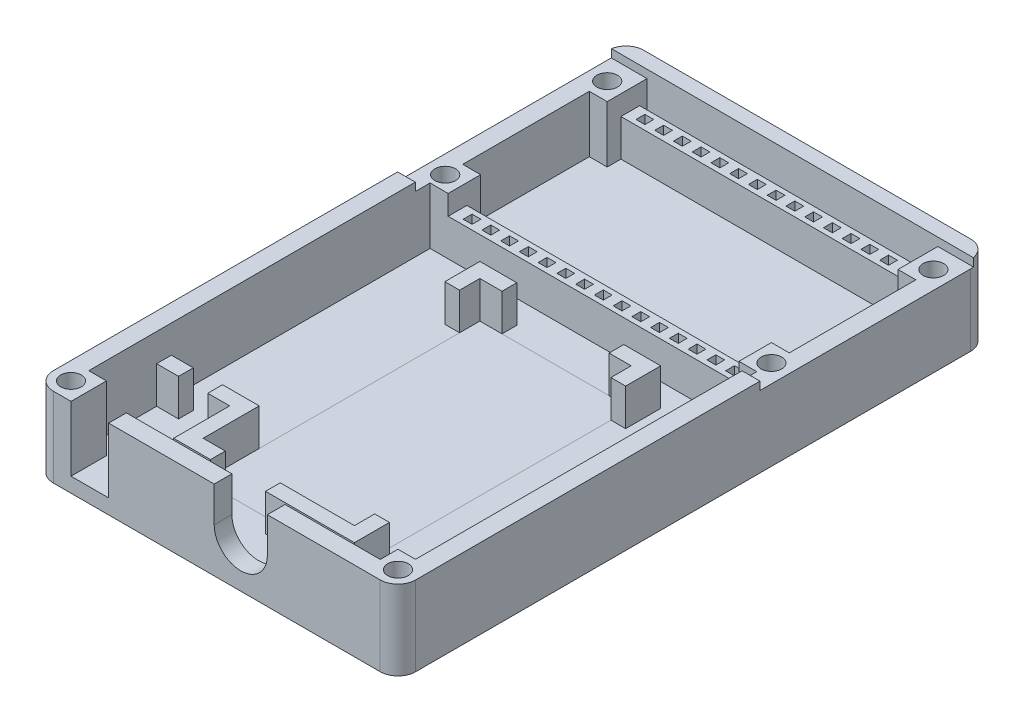
from build123d import *

# Parameters (mm, degrees)
SKETCH1_W           = 49.1
SKETCH1_H           = 80
BOSS_EXTRUDE1_DEPTH = 2
SKETCH2_R           = 1.4
CUT_EXTRUDE1_DEPTH  = 2
SKETCH3_R           = 1.4
SKETCH3_W           = 1.2
SKETCH3_H           = 1.2
BOSS_EXTRUDE2_DEPTH = 5
SKETCH4_W           = 4.85
SKETCH4_H           = 4.4
SKETCH4_R           = 1.4
BOSS_EXTRUDE3_DEPTH = 2.68
SKETCH5_W           = 7.047350567
SKETCH5_H           = 2
SKETCH5_W_2         = 0.952649433
BOSS_EXTRUDE4_DEPTH = 5
SKETCH6_W           = 4.8
SKETCH6_H           = 4.8
SKETCH6_R           = 1.4
BOSS_EXTRUDE5_DEPTH = 8.78
SKETCH7_W           = 2.4
SKETCH7_H           = 46.25
SKETCH7_W_2         = 2.425
SKETCH7_W_3         = 39.5
SKETCH7_H_2         = 2.4
BOSS_EXTRUDE6_DEPTH = 8.78
CUT_EXTRUDE2_DEPTH  = 2.4
SKETCH11_R          = 1.4
CUT_EXTRUDE4_DEPTH  = 2
SKETCH13_W          = 2.97
SKETCH13_H          = 2
BOSS_EXTRUDE7_DEPTH = 5
SKETCH14_W          = 2.425
SKETCH14_H          = 17.15
BOSS_EXTRUDE8_DEPTH = 2.68
CUT_EXTRUDE5_DEPTH  = 5
SKETCH17_W          = 4.85
SKETCH17_H          = 0.6
SKETCH17_W_2        = 2.4
SKETCH17_H_2        = 2
SKETCH17_W_3        = 2.425
CUT_EXTRUDE6_DEPTH  = 1.1
FILLET1_R           = 2.4


with BuildPart() as part:
    # Sketch1 → Boss-Extrude1 (new body)
    with BuildSketch(Plane(origin=(0, 0, 0), x_dir=(1, 0, 0), z_dir=(0, 1, 0))):
        with Locations((24.55, -40)):
            Rectangle(SKETCH1_W, SKETCH1_H)
    extrude(amount=BOSS_EXTRUDE1_DEPTH)

    # Sketch2 → Cut-Extrude1 (cut)
    with BuildSketch(Plane(origin=(0, 2, 0), x_dir=(1, 0, 0), z_dir=(0, 1, 0))):
        with Locations((2.45, -5)):
            Circle(SKETCH2_R)
        with Locations((46.65, -5)):
            Circle(SKETCH2_R)
        with Locations((46.65, -26.95)):
            Circle(SKETCH2_R)
        with Locations((2.45, -26.95)):
            Circle(SKETCH2_R)
    extrude(amount=-CUT_EXTRUDE1_DEPTH, mode=Mode.SUBTRACT)

    # Sketch3 → Boss-Extrude2 (add)
    with BuildSketch(Plane(origin=(0, 2, 0), x_dir=(1, 0, 0), z_dir=(0, 1, 0))):
        Polygon((4.85, -3), (44.25, -3), (44.25, -2.6), (49.1, -2.6), (49.1, -3), (49.1, -28.95), (0, -28.95), (0, -3), (0, -2.6), (4.85, -2.6), align=None)
        with Locations((2.45, -5)):
            Circle(SKETCH3_R, mode=Mode.SUBTRACT)
        with Locations((2.45, -26.95)):
            Circle(SKETCH3_R, mode=Mode.SUBTRACT)
        with Locations((46.65, -5)):
            Circle(SKETCH3_R, mode=Mode.SUBTRACT)
        with Locations((46.65, -26.95)):
            Circle(SKETCH3_R, mode=Mode.SUBTRACT)
        with Locations((6.82, -4.27)):
            Rectangle(SKETCH3_W, SKETCH3_H, mode=Mode.SUBTRACT)
        with Locations((9.36, -4.27)):
            Rectangle(SKETCH3_W, SKETCH3_H, mode=Mode.SUBTRACT)
        with Locations((11.9, -4.27)):
            Rectangle(SKETCH3_W, SKETCH3_H, mode=Mode.SUBTRACT)
        with Locations((14.44, -4.27)):
            Rectangle(SKETCH3_W, SKETCH3_H, mode=Mode.SUBTRACT)
        with Locations((16.98, -4.27)):
            Rectangle(SKETCH3_W, SKETCH3_H, mode=Mode.SUBTRACT)
        with Locations((19.52, -4.27)):
            Rectangle(SKETCH3_W, SKETCH3_H, mode=Mode.SUBTRACT)
        with Locations((22.06, -4.27)):
            Rectangle(SKETCH3_W, SKETCH3_H, mode=Mode.SUBTRACT)
        with Locations((24.6, -4.27)):
            Rectangle(SKETCH3_W, SKETCH3_H, mode=Mode.SUBTRACT)
        with Locations((27.14, -4.27)):
            Rectangle(SKETCH3_W, SKETCH3_H, mode=Mode.SUBTRACT)
        with Locations((29.68, -4.27)):
            Rectangle(SKETCH3_W, SKETCH3_H, mode=Mode.SUBTRACT)
        with Locations((32.22, -4.27)):
            Rectangle(SKETCH3_W, SKETCH3_H, mode=Mode.SUBTRACT)
        with Locations((34.76, -4.27)):
            Rectangle(SKETCH3_W, SKETCH3_H, mode=Mode.SUBTRACT)
        with Locations((37.3, -4.27)):
            Rectangle(SKETCH3_W, SKETCH3_H, mode=Mode.SUBTRACT)
        with Locations((39.84, -4.27)):
            Rectangle(SKETCH3_W, SKETCH3_H, mode=Mode.SUBTRACT)
        with Locations((42.38, -4.27)):
            Rectangle(SKETCH3_W, SKETCH3_H, mode=Mode.SUBTRACT)
        with Locations((42.38, -27.68)):
            Rectangle(SKETCH3_W, SKETCH3_H, mode=Mode.SUBTRACT)
        with Locations((39.84, -27.68)):
            Rectangle(SKETCH3_W, SKETCH3_H, mode=Mode.SUBTRACT)
        with Locations((37.3, -27.68)):
            Rectangle(SKETCH3_W, SKETCH3_H, mode=Mode.SUBTRACT)
        with Locations((34.76, -27.68)):
            Rectangle(SKETCH3_W, SKETCH3_H, mode=Mode.SUBTRACT)
        with Locations((32.22, -27.68)):
            Rectangle(SKETCH3_W, SKETCH3_H, mode=Mode.SUBTRACT)
        with Locations((29.68, -27.68)):
            Rectangle(SKETCH3_W, SKETCH3_H, mode=Mode.SUBTRACT)
        with Locations((27.14, -27.68)):
            Rectangle(SKETCH3_W, SKETCH3_H, mode=Mode.SUBTRACT)
        with Locations((24.6, -27.68)):
            Rectangle(SKETCH3_W, SKETCH3_H, mode=Mode.SUBTRACT)
        with Locations((22.06, -27.68)):
            Rectangle(SKETCH3_W, SKETCH3_H, mode=Mode.SUBTRACT)
        with Locations((19.52, -27.68)):
            Rectangle(SKETCH3_W, SKETCH3_H, mode=Mode.SUBTRACT)
        with Locations((16.98, -27.68)):
            Rectangle(SKETCH3_W, SKETCH3_H, mode=Mode.SUBTRACT)
        with Locations((14.44, -27.68)):
            Rectangle(SKETCH3_W, SKETCH3_H, mode=Mode.SUBTRACT)
        with Locations((11.9, -27.68)):
            Rectangle(SKETCH3_W, SKETCH3_H, mode=Mode.SUBTRACT)
        with Locations((9.36, -27.68)):
            Rectangle(SKETCH3_W, SKETCH3_H, mode=Mode.SUBTRACT)
        with Locations((6.82, -27.68)):
            Rectangle(SKETCH3_W, SKETCH3_H, mode=Mode.SUBTRACT)
    extrude(amount=BOSS_EXTRUDE2_DEPTH)

    # Sketch4 → Boss-Extrude3 (add)
    with BuildSketch(Plane(origin=(0, 7, 0), x_dir=(1, 0, 0), z_dir=(0, 1, 0))):
        with Locations((2.425, -26.75)):
            Rectangle(SKETCH4_W, SKETCH4_H)
        with Locations((2.45, -26.95)):
            Circle(SKETCH4_R, mode=Mode.SUBTRACT)
        with Locations((46.675, -26.75)):
            Rectangle(SKETCH4_W, SKETCH4_H)
        with Locations((46.65, -26.95)):
            Circle(SKETCH4_R, mode=Mode.SUBTRACT)
        Polygon((49.1, -7.4), (49.1, -3), (49.1, -2.6), (44.25, -2.6), (44.25, -3), (44.25, -7.4), align=None)
        with Locations((46.65, -5)):
            Circle(SKETCH4_R, mode=Mode.SUBTRACT)
        Polygon((4.85, -7.4), (4.85, -3), (4.85, -2.6), (0, -2.6), (0, -3), (0, -7.4), align=None)
        with Locations((2.45, -5)):
            Circle(SKETCH4_R, mode=Mode.SUBTRACT)
    extrude(amount=BOSS_EXTRUDE3_DEPTH)

    # Sketch5 → Boss-Extrude4 (add)
    with BuildSketch(Plane(origin=(0, 2, 0), x_dir=(1, 0, 0), z_dir=(0, 1, 0))):
        Polygon((14.3, -36.85), (14.3, -34.1), (17.3, -34.1), (17.3, -32.1), (12.3, -32.1), (12.3, -36.85), align=None)
        Polygon((31.8, -32.1), (31.8, -34.1), (34.8, -34.1), (34.8, -36.85), (36.8, -36.85), (36.8, -32.1), align=None)
        Polygon((36.8, -68.85), (34.8, -68.85), (34.8, -71.6), (32.752649433, -71.6), (32.752649433, -73.6), (36.8, -73.6), align=None)
        Polygon((14.3, -71.6), (14.3, -68.85), (12.3, -68.85), (12.3, -73.6), (17.3, -73.6), (17.3, -71.6), align=None)
        with Locations((28.276324716, -72.6)):
            Rectangle(SKETCH5_W, SKETCH5_H)
        with Locations((32.276324716, -72.6)):
            Rectangle(SKETCH5_W_2, SKETCH5_H)
    extrude(amount=BOSS_EXTRUDE4_DEPTH)

    # Sketch6 → Boss-Extrude5 (add)
    with BuildSketch(Plane(origin=(0, 2, 0), x_dir=(1, 0, 0), z_dir=(0, 1, 0))):
        with Locations((2.4, -77.6)):
            Rectangle(SKETCH6_W, SKETCH6_H)
        with Locations((2.4, -77.6)):
            Circle(SKETCH6_R, mode=Mode.SUBTRACT)
        with Locations((46.7, -77.6)):
            Rectangle(SKETCH6_W, SKETCH6_H)
        with Locations((46.7, -77.6)):
            Circle(SKETCH6_R, mode=Mode.SUBTRACT)
    extrude(amount=BOSS_EXTRUDE5_DEPTH)

    # Sketch7 → Boss-Extrude6 (add)
    with BuildSketch(Plane(origin=(0, 2, 0), x_dir=(1, 0, 0), z_dir=(0, 1, 0))):
        with Locations((1.2, -52.075)):
            Rectangle(SKETCH7_W, SKETCH7_H)
        with Locations((47.8875, -52.075)):
            Rectangle(SKETCH7_W_2, SKETCH7_H)
        Polygon((0, 0), (49.1, 0), (49.1, -2), (49.1, -2.6), (44.25, -2.6), (44.25, -2), (4.85, -2), (4.85, -2.6), (0, -2.6), (0, -2), align=None)
        with Locations((24.55, -78.8)):
            Rectangle(SKETCH7_W_3, SKETCH7_H_2)
    extrude(amount=BOSS_EXTRUDE6_DEPTH)

    # Sketch8 → Cut-Extrude2 (cut)
    with BuildSketch(Plane.XY.offset(80)):
        Polygon((4.8, 8.2), (4.8, 2), (9.9, 2), (9.9, 8.2), (9.9, 10.78), (4.8, 10.78), align=None)
        with BuildLine():
            Line((24.2, 6), (24.2, 10.78))
            Line((24.2, 10.78), (31.4, 10.78))
            Line((31.4, 10.78), (31.4, 6))
            ThreePointArc((31.4, 6), (27.8, 2.4), (24.2, 6))
        make_face()
    extrude(amount=-CUT_EXTRUDE2_DEPTH, mode=Mode.SUBTRACT)

    # Sketch11 → Cut-Extrude4 (cut)
    with BuildSketch(Plane(origin=(0, 2, 0), x_dir=(1, 0, 0), z_dir=(0, 1, 0))):
        with Locations((2.4, -77.6)):
            Circle(SKETCH11_R)
        with Locations((46.7, -77.6)):
            Circle(SKETCH11_R)
    extrude(amount=-CUT_EXTRUDE4_DEPTH, mode=Mode.SUBTRACT)

    # Sketch13 → Boss-Extrude7 (add)
    with BuildSketch(Plane(origin=(0, 2, 0), x_dir=(1, 0, 0), z_dir=(0, 1, 0))):
        Polygon((12.3, -66), (9.33, -66), (9.33, -64), (14.3, -64), (14.3, -66), (14.3, -68.85), (12.3, -68.85), align=None)
        with Locations((3.885, -65)):
            Rectangle(SKETCH13_W, SKETCH13_H)
    extrude(amount=BOSS_EXTRUDE7_DEPTH)

    # Sketch14 → Boss-Extrude8 (add)
    with BuildSketch(Plane(origin=(0, 7, 0), x_dir=(1, 0, 0), z_dir=(0, 1, 0))):
        with Locations((47.8875, -15.975)):
            Rectangle(SKETCH14_W, SKETCH14_H)
        with Locations((1.2125, -15.975)):
            Rectangle(SKETCH14_W, SKETCH14_H)
    extrude(amount=BOSS_EXTRUDE8_DEPTH)

    # Sketch16 → Cut-Extrude5 (cut)
    with BuildSketch(Plane(origin=(0, 7, 0), x_dir=(1, 0, 0), z_dir=(0, 1, 0))):
        Polygon((4.85, -24.55), (4.85, -26.41), (44.25, -26.41), (44.25, -24.55), (46.675, -24.55), (46.675, -7.4), (44.25, -7.4), (44.25, -5.54), (4.85, -5.54), (4.85, -7.4), (2.425, -7.4), (2.425, -24.55), align=None)
    extrude(amount=-CUT_EXTRUDE5_DEPTH, mode=Mode.SUBTRACT)

    # Sketch17 → Cut-Extrude6 (cut)
    with BuildSketch(Plane(origin=(0, 10.78, 0), x_dir=(1, 0, 0), z_dir=(0, 1, 0))):
        with Locations((2.425, -2.3)):
            Rectangle(SKETCH17_W, SKETCH17_H)
        with Locations((46.675, -2.3)):
            Rectangle(SKETCH17_W, SKETCH17_H)
        with Locations((1.2, -29.95)):
            Rectangle(SKETCH17_W_2, SKETCH17_H_2)
        with Locations((47.8875, -29.95)):
            Rectangle(SKETCH17_W_3, SKETCH17_H_2)
    extrude(amount=-CUT_EXTRUDE6_DEPTH, mode=Mode.SUBTRACT)

    # Fillet1
    fillet1_edges = [part.edges().sort_by_distance(p)[0] for p in [
        (0, 5.39, 80),
        (49.1, 5.39, 80),
        (49.1, 5.39, 0),
        (0, 5.39, 0),
    ]]
    fillet(fillet1_edges, radius=FILLET1_R)


solid = part.part
